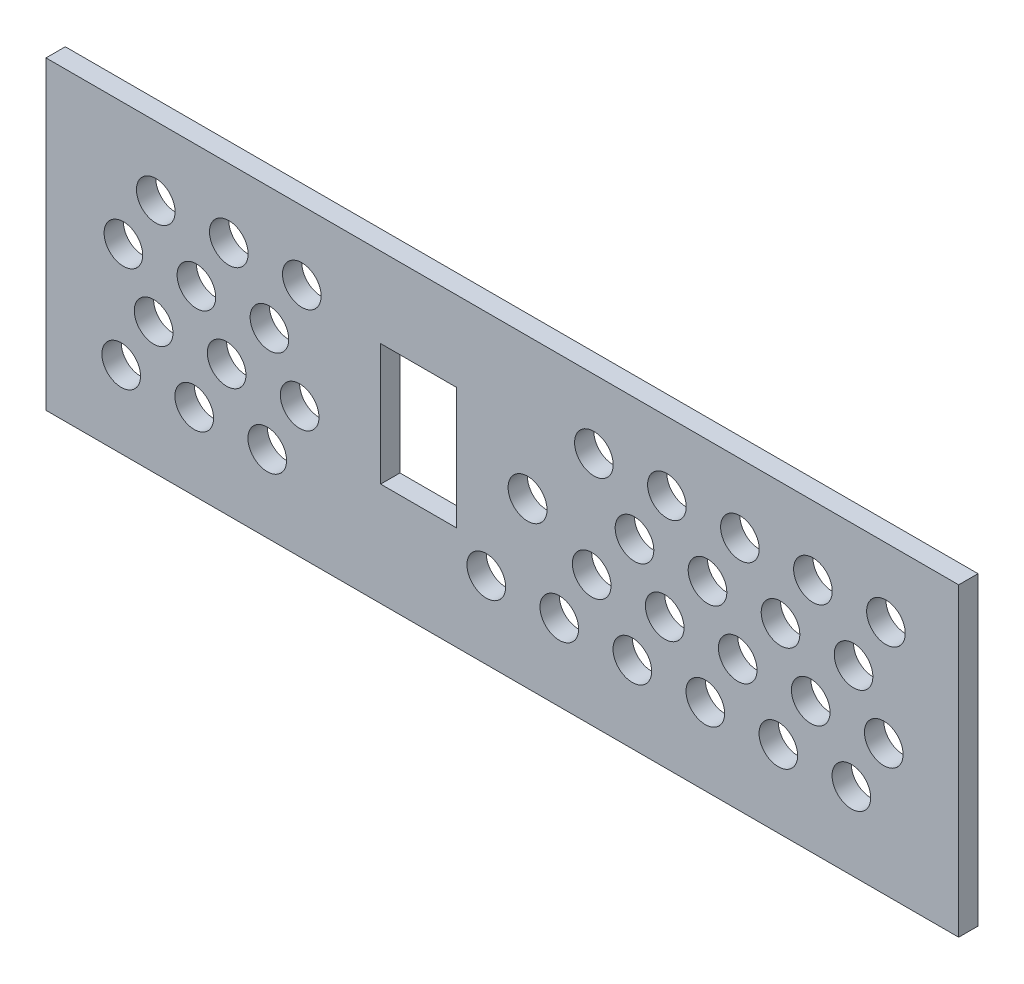
from build123d import *

# Parameters (mm, degrees)
BOSS_EXTRUDE1_DEPTH   = 3.175
BOSS_EXTRUDE1_2_DEPTH = 3.175
BOSS_EXTRUDE1_3_DEPTH = 3.175
BOSS_EXTRUDE1_4_DEPTH = 3.175
SKETCH1_R             = 3.2
SKETCH1_W             = 12.5
SKETCH1_H             = 20
BOSS_EXTRUDE1_5_DEPTH = 3.175
SKETCH2_W             = 43.267164734
SKETCH2_H             = 48
SKETCH2_W_2           = 36.488078293
BOSS_EXTRUDE2_DEPTH   = 3.175
SKETCH3_W             = 150
SKETCH3_H             = 50.164895034
SKETCH3_W_2           = 146
SKETCH3_H_2           = 48
BOSS_EXTRUDE3_DEPTH   = 3.175
SKETCH4_R             = 3.175
CUT_EXTRUDE1_DEPTH    = 3.175


with BuildPart() as part:
    # Sketch1 → Boss-Extrude1 (new body)
    with BuildSketch(Plane.XY):
        Polygon((57.693747285, -13.75), (57.693747285, -24), (73, -24), (73, -10.75), (53.098076211, -10.75), (53.098076211, -13.75), align=None)
    extrude(amount=BOSS_EXTRUDE1_DEPTH)



with BuildPart() as body_2:
    # Sketch1 → Boss-Extrude1 2 (new body)
    with BuildSketch(Plane.XY):
        Polygon((53.098076211, 13.25), (73, 13.25), (73, 24), (57.693747285, 24), (57.693747285, 16.25), (53.098076211, 16.25), align=None)
    extrude(amount=BOSS_EXTRUDE1_2_DEPTH)


with BuildPart() as body_3:
    # Sketch1 → Boss-Extrude1 3 (new body)
    with BuildSketch(Plane.XY):
        Polygon((-73, -10.75), (-73, -24), (-57.693747285, -24), (-57.693747285, -13.75), (-53.098076211, -13.75), (-53.098076211, -10.75), align=None)
    extrude(amount=BOSS_EXTRUDE1_3_DEPTH)


with BuildPart() as body_4:
    # Sketch1 → Boss-Extrude1 4 (new body)
    with BuildSketch(Plane.XY):
        Polygon((-57.693747285, 24), (-73, 24), (-73, 13.25), (-53.098076211, 13.25), (-53.098076211, 16.25), (-57.693747285, 16.25), align=None)
    extrude(amount=BOSS_EXTRUDE1_4_DEPTH)


with BuildPart() as body_5:
    # Sketch1 → Boss-Extrude1 5 (new body)
    with BuildSketch(Plane.XY):
        Polygon((-43.306252715, -13.75), (-43.306252715, -24), (43.306252715, -24), (43.306252715, -13.75), (47.901923789, -13.75), (47.901923789, -6.75), (47.33772234, -6.75), (47.33772234, 9.25), (47.901923789, 9.25), (47.901923789, 16.25), (43.306252715, 16.25), (43.306252715, 24), (-43.306252715, 24), (-43.306252715, 16.25), (-47.901923789, 16.25), (-47.901923789, 9.25), (-47.33772234, 9.25), (-47.33772234, -6.75), (-47.901923789, -6.75), (-47.901923789, -13.75), align=None)
        with Locations((4.144011572, 1)):
            Circle(SKETCH1_R, mode=Mode.SUBTRACT)
        with Locations((-13.75, 1)):
            Rectangle(SKETCH1_W, SKETCH1_H, mode=Mode.SUBTRACT)
    extrude(amount=BOSS_EXTRUDE1_5_DEPTH)


with BuildPart() as part_1:
    add(part.part)

    add(body_2.part)  # Boss-Extrude2 merges body 2

    add(body_3.part)  # Boss-Extrude2 merges body 3

    add(body_4.part)  # Boss-Extrude2 merges body 4

    add(body_5.part)  # Boss-Extrude2 merges body 5
    # Sketch2 → Boss-Extrude2 (add)
    with BuildSketch(Plane.XY.offset(3.175)):
        with Locations((-51.366417633, 0)):
            Rectangle(SKETCH2_W, SKETCH2_H)
        with Locations((54.755960853, 0)):
            Rectangle(SKETCH2_W_2, SKETCH2_H)
    extrude(amount=-BOSS_EXTRUDE2_DEPTH)

    # Sketch3 → Boss-Extrude3 (add)
    with BuildSketch(Plane.XY.offset(3.175)):
        with Locations((0, -0.917552483)):
            Rectangle(SKETCH3_W, SKETCH3_H)
        Rectangle(SKETCH3_W_2, SKETCH3_H_2, mode=Mode.SUBTRACT)
    extrude(amount=-BOSS_EXTRUDE3_DEPTH)

    # Sketch4 → Cut-Extrude1 (cut)
    with BuildSketch(Plane.XY.offset(3.175)):
        with Locations((-56.95575683, 12.857770953)):
            Circle(SKETCH4_R)
        with Locations((-44.95575683, 12.857770953)):
            Circle(SKETCH4_R)
        with Locations((-32.95575683, 12.857770953)):
            Circle(SKETCH4_R)
        with Locations((15.04424317, 12.857770953)):
            Circle(SKETCH4_R)
        with Locations((27.04424317, 12.857770953)):
            Circle(SKETCH4_R)
        with Locations((39.04424317, 12.857770953)):
            Circle(SKETCH4_R)
        with Locations((51.04424317, 12.857770953)):
            Circle(SKETCH4_R)
        with Locations((63.04424317, 12.857770953)):
            Circle(SKETCH4_R)
        with Locations((-62.280718202, 4.034960141)):
            Circle(SKETCH4_R)
        with Locations((-50.280718202, 4.034960141)):
            Circle(SKETCH4_R)
        with Locations((-38.280718202, 4.034960141)):
            Circle(SKETCH4_R)
        with Locations((21.719281798, 4.034960141)):
            Circle(SKETCH4_R)
        with Locations((33.719281798, 4.034960141)):
            Circle(SKETCH4_R)
        with Locations((45.719281798, 4.034960141)):
            Circle(SKETCH4_R)
        with Locations((57.719281798, 4.034960141)):
            Circle(SKETCH4_R)
        with Locations((-57.312596917, -4.551617996)):
            Circle(SKETCH4_R)
        with Locations((-45.312596917, -4.551617996)):
            Circle(SKETCH4_R)
        with Locations((-33.312596917, -4.551617996)):
            Circle(SKETCH4_R)
        with Locations((14.687403083, -4.551617996)):
            Circle(SKETCH4_R)
        with Locations((26.687403083, -4.551617996)):
            Circle(SKETCH4_R)
        with Locations((38.687403083, -4.551617996)):
            Circle(SKETCH4_R)
        with Locations((50.687403083, -4.551617996)):
            Circle(SKETCH4_R)
        with Locations((62.687403083, -4.551617996)):
            Circle(SKETCH4_R)
        with Locations((-62.637558288, -13.374428808)):
            Circle(SKETCH4_R)
        with Locations((-50.637558288, -13.374428808)):
            Circle(SKETCH4_R)
        with Locations((-38.637558288, -13.374428808)):
            Circle(SKETCH4_R)
        with Locations((-2.637558288, -13.374428808)):
            Circle(SKETCH4_R)
        with Locations((9.362441712, -13.374428808)):
            Circle(SKETCH4_R)
        with Locations((21.362441712, -13.374428808)):
            Circle(SKETCH4_R)
        with Locations((33.362441712, -13.374428808)):
            Circle(SKETCH4_R)
        with Locations((45.362441712, -13.374428808)):
            Circle(SKETCH4_R)
        with Locations((57.362441712, -13.374428808)):
            Circle(SKETCH4_R)
    extrude(amount=-CUT_EXTRUDE1_DEPTH, mode=Mode.SUBTRACT)


solid = part_1.part
